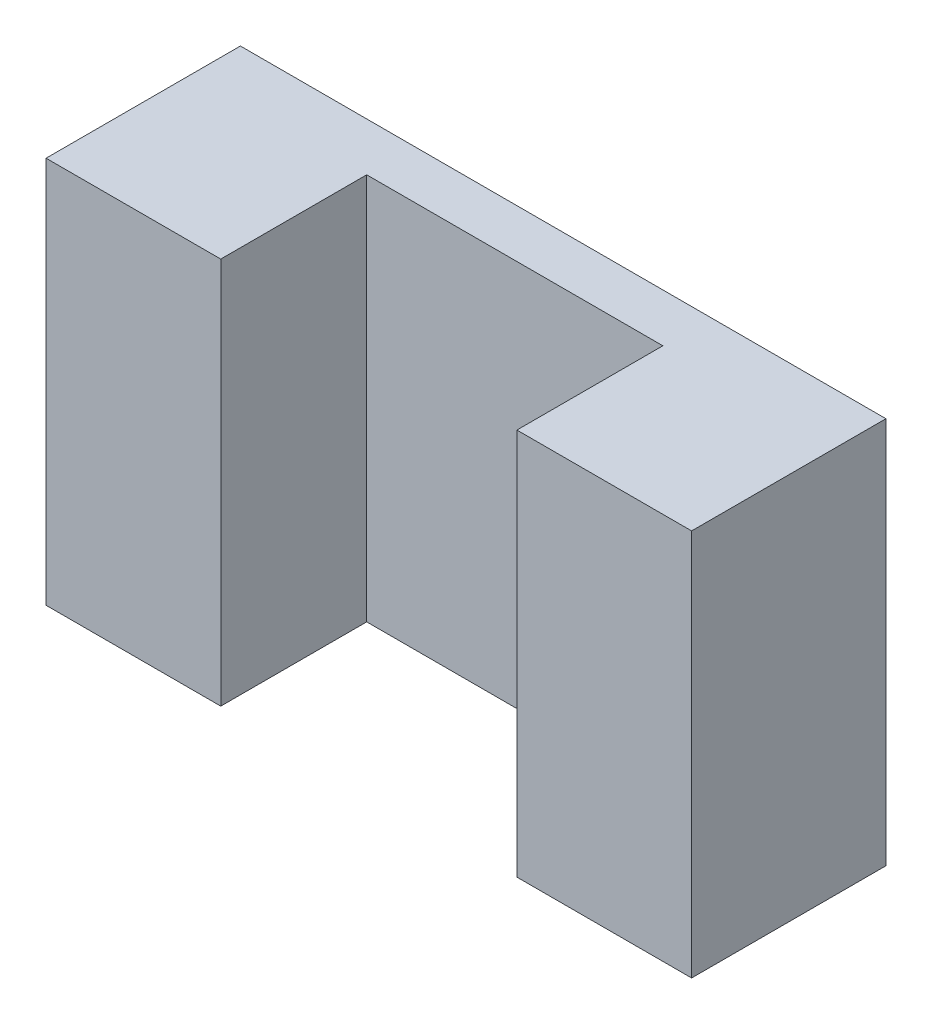
from build123d import *

# Parameters (mm, degrees)
SKETCH1_W           = 66.43745389
SKETCH1_H           = 39.85
BOSS_EXTRUDE1_DEPTH = 20
SKETCH2_W           = 30.48
SKETCH2_H           = 39.85
CUT_EXTRUDE1_DEPTH  = 15.02


with BuildPart() as part:
    # Sketch1 → Boss-Extrude1 (new body)
    with BuildSketch(Plane.XY):
        Rectangle(SKETCH1_W, SKETCH1_H)
    extrude(amount=BOSS_EXTRUDE1_DEPTH)

    # Sketch2 → Cut-Extrude1 (cut)
    with BuildSketch(Plane.XY.offset(20)):
        Rectangle(SKETCH2_W, SKETCH2_H)
    extrude(amount=-CUT_EXTRUDE1_DEPTH, mode=Mode.SUBTRACT)


solid = part.part
